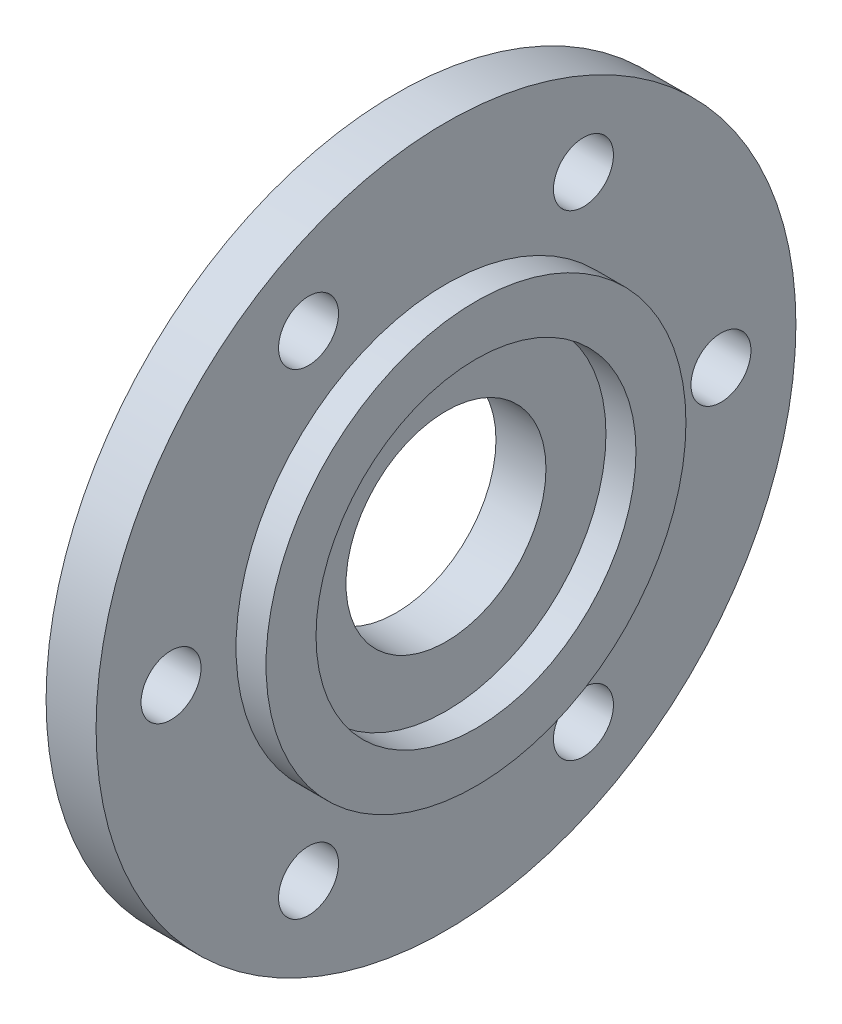
from build123d import *

# Parameters (mm, degrees)
SKETCH2_R          = 3
CUT_EXTRUDE1_DEPTH = 10
CIRPATTERN1_COUNT  = 6
SKETCH3_R          = 10
CUT_EXTRUDE2_DEPTH = 10


with BuildPart() as part:
    # Sketch1 → Revolve1 (revolve)
    with BuildSketch(Plane.XY):
        Polygon((0, 35), (5, 35), (5, 21), (8, 21), (8, 16), (5, 16), (5, 0), (0, 0), align=None)
    revolve(axis=Axis((5, 0, 0), (-1, 0, 0)))

    # Sketch2 → Cut-Extrude1 (cut)
    with BuildSketch(Plane(origin=(5, 0, 0), x_dir=(0, 0, -1), z_dir=(1, 0, 0))):
        with Locations((27.5, 0)):
            Circle(SKETCH2_R)
    cut_extrude1 = extrude(amount=-CUT_EXTRUDE1_DEPTH, mode=Mode.SUBTRACT)

    # CirPattern1: Cut-Extrude1 ×6 about axis
    cirpattern1_axis = Axis((0, 0, 0), (1, 0, 0))
    for i in range(1, CIRPATTERN1_COUNT):
        add(cut_extrude1.rotate(cirpattern1_axis, i * 360 / CIRPATTERN1_COUNT), mode=Mode.SUBTRACT)

    # Sketch3 → Cut-Extrude2 (cut)
    with BuildSketch(Plane(origin=(5, 0, 0), x_dir=(0, 0, -1), z_dir=(1, 0, 0))):
        Circle(SKETCH3_R)
    extrude(amount=-CUT_EXTRUDE2_DEPTH, mode=Mode.SUBTRACT)


solid = part.part
